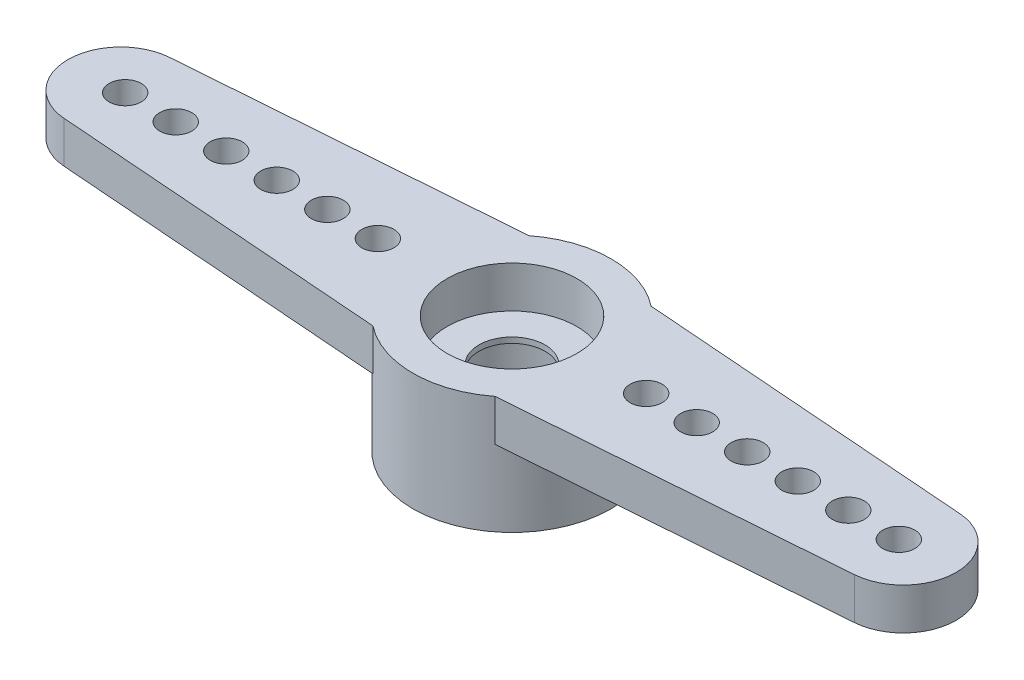
from build123d import *

# Parameters (mm, degrees)
SKETCH1_R               = 2.345
EXTRUDE1_DEPTH          = 1.5
SKETCH2_R               = 3.58
SKETCH2_R_2             = 2.18
EXTRUDE2_DEPTH          = 2.74
SKETCH3_R               = 2.345
SKETCH3_R_2             = 1.195
EXTRUDE3_DEPTH          = 0.2
SKETCH4_R               = 0.58
EXTRUDE4_DEPTH          = 5.24
LPATTERN1_COUNT         = 6
LPATTERN1_PITCH         = 1.825
MIRROR1_COPY_1_SKETCH_R = 0.58
MIRROR1_COPY_1_DEPTH    = 5.24
MIRROR1_COPY_2_SKETCH_R = 0.58
MIRROR1_COPY_2_DEPTH    = 5.24
MIRROR1_COPY_3_SKETCH_R = 0.58
MIRROR1_COPY_3_DEPTH    = 5.24
MIRROR1_COPY_4_SKETCH_R = 0.58
MIRROR1_COPY_4_DEPTH    = 5.24
MIRROR1_COPY_5_SKETCH_R = 0.58
MIRROR1_COPY_5_DEPTH    = 5.24


with BuildPart() as part:
    # Sketch1 → Extrude1 (new body)
    with BuildSketch(Plane(origin=(0, 0, 0), x_dir=(1, 0, 0), z_dir=(0, 1, 0))):
        with BuildLine():
            Line((-14.274464235, -1.904528835), (-2.2054478, -2.82))
            ThreePointArc((-2.2054478, -2.82), (0, -3.58), (2.2054478, -2.82))
            Line((2.2054478, -2.82), (14.274464235, -1.904528835))
            ThreePointArc((14.274464235, -1.904528835), (16.04, 0), (14.274464235, 1.904528835))
            Line((14.274464235, 1.904528835), (2.2054478, 2.82))
            ThreePointArc((2.2054478, 2.82), (0, 3.58), (-2.2054478, 2.82))
            Line((-2.2054478, 2.82), (-14.274464235, 1.904528835))
            ThreePointArc((-14.274464235, 1.904528835), (-16.04, 0), (-14.274464235, -1.904528835))
        make_face()
        with Locations(Location((0, 0, 0), (0, 0, 270))):  # turned: the seam where the file's is
            Circle(SKETCH1_R, mode=Mode.SUBTRACT)
    extrude(amount=EXTRUDE1_DEPTH)

    # Sketch2 → Extrude2 (add)
    with BuildSketch(Plane.XZ):
        with Locations(Location((0, 0, 0), (0, 0, 270))):  # turned: the seam where the file's is
            Circle(SKETCH2_R)
        with Locations(Location((0, 0, 0), (0, 0, 270))):  # turned: the seam where the file's is
            Circle(SKETCH2_R_2, mode=Mode.SUBTRACT)
    extrude(amount=EXTRUDE2_DEPTH)

    # Sketch3 → Extrude3 (add)
    with BuildSketch(Plane(origin=(0, 0, 0), x_dir=(-1, 0, 0), z_dir=(0, 1, 0))):
        with Locations(Location((0, 0, 0), (0, 0, 90))):  # turned: the seam where the file's is
            Circle(SKETCH3_R)
        with Locations(Location((0, 0, 0), (0, 0, 90))):  # turned: the seam where the file's is
            Circle(SKETCH3_R_2, mode=Mode.SUBTRACT)
    extrude(amount=-EXTRUDE3_DEPTH)

    # Sketch4 → Extrude4 (cut, through all)
    with BuildSketch(Plane(origin=(0, 1.5, 0), x_dir=(1, 0, 0), z_dir=(0, 1, 0))):
        with Locations(Location((-4.845, 0, 0), (0, 0, 270))):  # turned: the seam where the file's is
            Circle(SKETCH4_R)
    extrude4 = extrude(amount=-EXTRUDE4_DEPTH, mode=Mode.SUBTRACT)

    # LPattern1: Extrude4 ×6
    with Locations(*[(-i * LPATTERN1_PITCH, 0, 0) for i in range(1, LPATTERN1_COUNT)]):
        add(extrude4, mode=Mode.SUBTRACT)

    # Mirror1: Extrude4 across plane
    add(extrude4.mirror(Plane(origin=(0, 0, 0), x_dir=(0, 0, 1), z_dir=(1, 0, 0))), mode=Mode.SUBTRACT)

    # Mirror1 copy 1 sketch → Mirror1 copy 1 (cut, through all)
    with BuildSketch(Plane(origin=(1.825, 1.5, 0), x_dir=(-1, 0, 0), z_dir=(0, 1, 0))):
        with Locations((-4.845, 0)):
            Circle(MIRROR1_COPY_1_SKETCH_R)
    extrude(amount=-MIRROR1_COPY_1_DEPTH, mode=Mode.SUBTRACT)

    # Mirror1 copy 2 sketch → Mirror1 copy 2 (cut, through all)
    with BuildSketch(Plane(origin=(3.65, 1.5, 0), x_dir=(-1, 0, 0), z_dir=(0, 1, 0))):
        with Locations((-4.845, 0)):
            Circle(MIRROR1_COPY_2_SKETCH_R)
    extrude(amount=-MIRROR1_COPY_2_DEPTH, mode=Mode.SUBTRACT)

    # Mirror1 copy 3 sketch → Mirror1 copy 3 (cut, through all)
    with BuildSketch(Plane(origin=(5.475, 1.5, 0), x_dir=(-1, 0, 0), z_dir=(0, 1, 0))):
        with Locations((-4.845, 0)):
            Circle(MIRROR1_COPY_3_SKETCH_R)
    extrude(amount=-MIRROR1_COPY_3_DEPTH, mode=Mode.SUBTRACT)

    # Mirror1 copy 4 sketch → Mirror1 copy 4 (cut, through all)
    with BuildSketch(Plane(origin=(7.3, 1.5, 0), x_dir=(-1, 0, 0), z_dir=(0, 1, 0))):
        with Locations((-4.845, 0)):
            Circle(MIRROR1_COPY_4_SKETCH_R)
    extrude(amount=-MIRROR1_COPY_4_DEPTH, mode=Mode.SUBTRACT)

    # Mirror1 copy 5 sketch → Mirror1 copy 5 (cut, through all)
    with BuildSketch(Plane(origin=(9.125, 1.5, 0), x_dir=(-1, 0, 0), z_dir=(0, 1, 0))):
        with Locations((-4.845, 0)):
            Circle(MIRROR1_COPY_5_SKETCH_R)
    extrude(amount=-MIRROR1_COPY_5_DEPTH, mode=Mode.SUBTRACT)


solid = part.part
